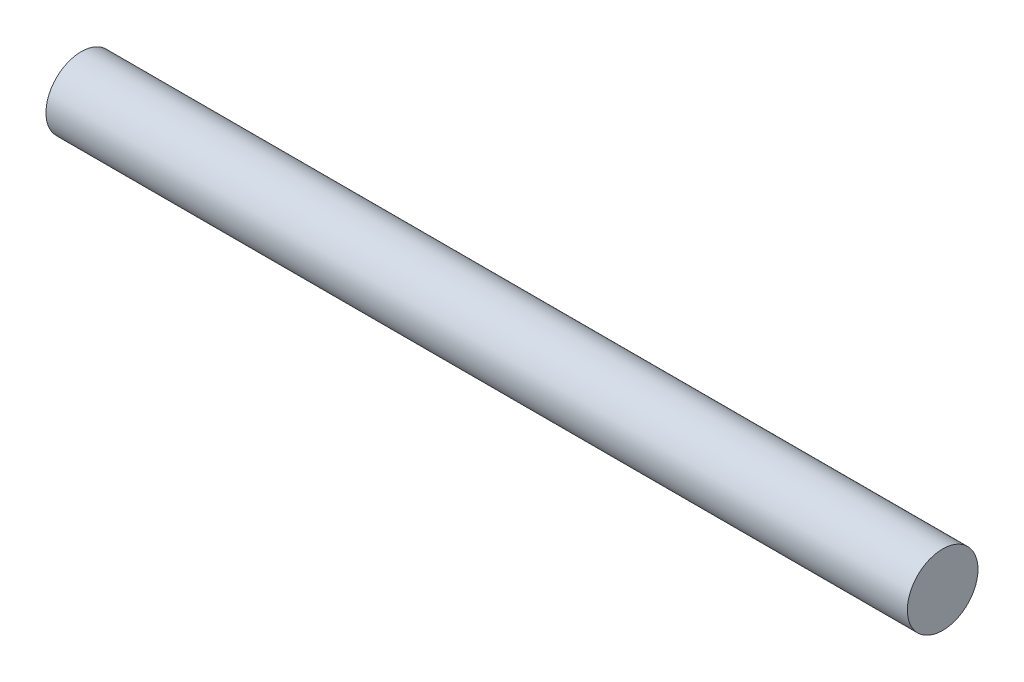
from build123d import *

# Parameters (mm, degrees)
SKETCH1_R           = 4
BOSS_EXTRUDE1_DEPTH = 97.5


with BuildPart() as part:
    # Sketch1 → Boss-Extrude1 (new body)
    with BuildSketch(Plane(origin=(0, 0, 0), x_dir=(0, 0, -1), z_dir=(1, 0, 0))):
        Circle(SKETCH1_R)
    extrude(amount=BOSS_EXTRUDE1_DEPTH)


solid = part.part
